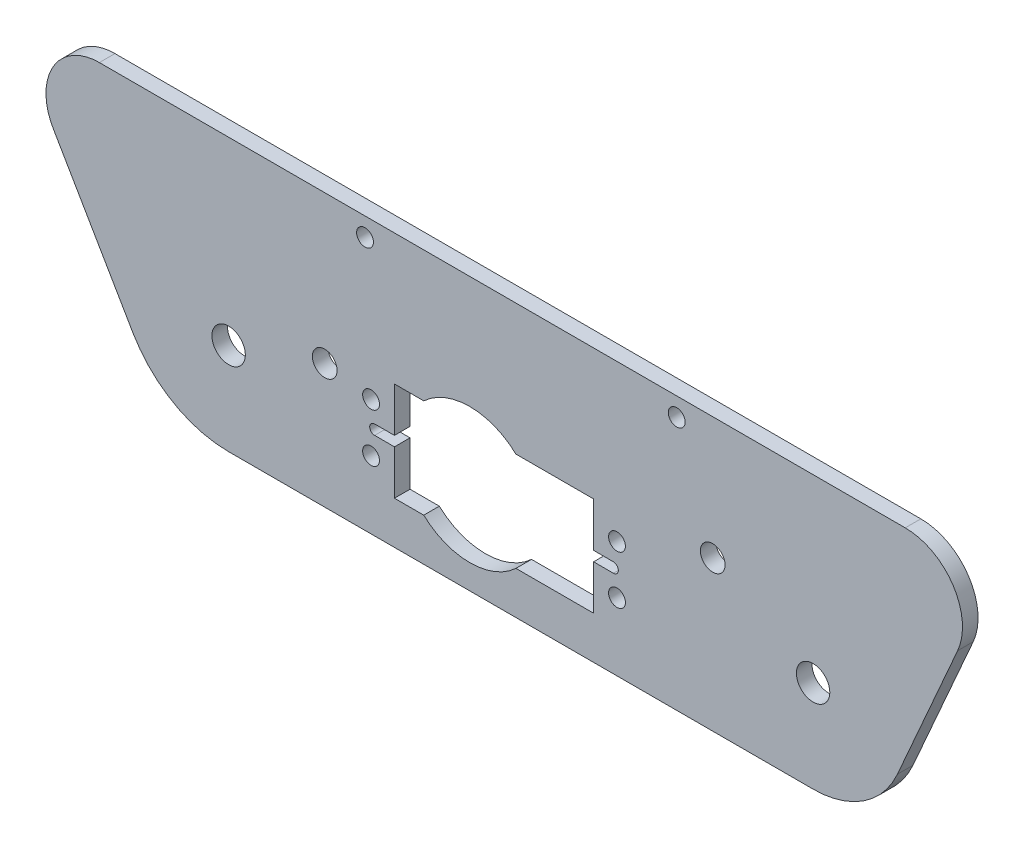
from build123d import *

# Parameters (mm, degrees)
SKETCH1_R           = 3.429
SKETCH1_R_2         = 2.54
BOSS_EXTRUDE1_DEPTH = 3.2004
SKETCH2_R           = 1.7272
CUT_EXTRUDE1_DEPTH  = 3.2004
SKETCH5_R           = 1.7272
SKETCH5_W           = 40.894
SKETCH5_H           = 20.32
CUT_EXTRUDE3_DEPTH  = 4.2004
CUT_EXTRUDE4_DEPTH  = 3.2004
SKETCH9_R           = 13.885201093
CUT_EXTRUDE7_DEPTH  = 3.2004


with BuildPart() as part:
    # Sketch1 → Boss-Extrude1 (new body)
    with BuildSketch(Plane.XY):
        with BuildLine():
            Line((0, 0), (120.015, 0))
            ThreePointArc((120.015, 0), (130.351788397, 3.075697789), (137.325636158, 11.302152593))
            Line((137.325636158, 11.302152593), (149.69326877, 39.451329485))
            ThreePointArc((149.69326877, 39.451329485), (148.774539583, 50.600046625), (138.937102863, 55.925719911))
            Line((138.937102863, 55.925719911), (-26.54325766, 55.925719911))
            ThreePointArc((-26.54325766, 55.925719911), (-36.046025914, 50.429200208), (-36.019801229, 39.451329485))
            Line((-36.019801229, 39.451329485), (-19.648099871, 11.302152593))
            ThreePointArc((-19.648099871, 11.302152593), (-11.333429333, 3.027112684), (0, 0))
        make_face()
        with Locations((120.015, 18.90776)):
            Circle(SKETCH1_R, mode=Mode.SUBTRACT)
        with Locations((0, 18.90776)):
            Circle(SKETCH1_R, mode=Mode.SUBTRACT)
        with Locations((19.734727626, 25.566426992)):
            Circle(SKETCH1_R_2, mode=Mode.SUBTRACT)
        with Locations((99.400822531, 30.809360911)):
            Circle(SKETCH1_R_2, mode=Mode.SUBTRACT)
    extrude(amount=BOSS_EXTRUDE1_DEPTH)

    # Sketch2 → Cut-Extrude1 (cut)
    with BuildSketch(Plane(origin=(0, 0, 0), x_dir=(-1, 0, 0), z_dir=(0, 0, -1))):
        with Locations((-92.0115, 52.115719911)):
            Circle(SKETCH2_R)
        with Locations((-28.0035, 52.115719911)):
            Circle(SKETCH2_R)
    extrude(amount=-CUT_EXTRUDE1_DEPTH, mode=Mode.SUBTRACT)

    # Sketch5 → Cut-Extrude3 (cut, through all)
    with BuildSketch(Plane(origin=(0, 0, 0), x_dir=(-1, 0, 0), z_dir=(0, 0, -1))):
        with Locations((-79.746999972, 23.90776)):
            Circle(SKETCH5_R)
        with Locations((-29.246999972, 13.90776)):
            Circle(SKETCH5_R)
        with Locations((-29.246999972, 23.90776)):
            Circle(SKETCH5_R)
        with Locations((-79.746999972, 13.90776)):
            Circle(SKETCH5_R)
        with Locations((-54.496999972, 18.90776)):
            Rectangle(SKETCH5_W, SKETCH5_H)
    extrude(amount=-CUT_EXTRUDE3_DEPTH, mode=Mode.SUBTRACT)

    # Sketch6 → Cut-Extrude4 (cut)
    with BuildSketch(Plane.XY.offset(3.2004)):
        with BuildLine():
            Line((29.985999972, 19.92376), (34.049999972, 19.92376))
            Line((34.049999972, 19.92376), (34.049999972, 17.89176))
            Line((34.049999972, 17.89176), (29.985999972, 17.89176))
            ThreePointArc((29.985999972, 17.89176), (28.969999972, 18.90776), (29.985999972, 19.92376))
        make_face()
        with BuildLine():
            Line((74.943999972, 19.92376), (79.007999972, 19.92376))
            ThreePointArc((79.007999972, 19.92376), (80.023999972, 18.90776), (79.007999972, 17.89176))
            Line((79.007999972, 17.89176), (74.943999972, 17.89176))
            Line((74.943999972, 17.89176), (74.943999972, 19.92376))
        make_face()
    extrude(amount=-CUT_EXTRUDE4_DEPTH, mode=Mode.SUBTRACT)

    # Sketch9 → Cut-Extrude7 (cut)
    with BuildSketch(Plane(origin=(0, 0, 0), x_dir=(-1, 0, 0), z_dir=(0, 0, -1))):
        with Locations((-49.53, 18.90776)):
            Circle(SKETCH9_R)
    extrude(amount=-CUT_EXTRUDE7_DEPTH, mode=Mode.SUBTRACT)


solid = part.part
